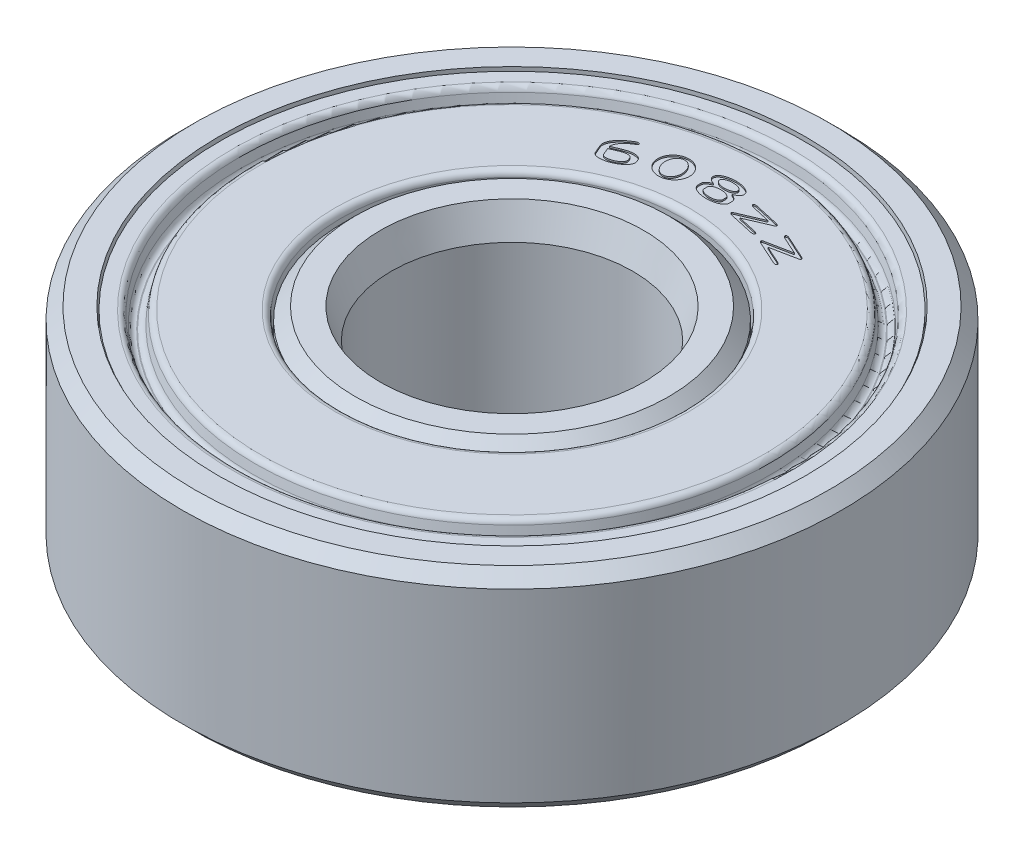
from build123d import *

# Parameters (mm, degrees)
SKETCH1_W             = 1.2
SKETCH1_H             = 6.98
CHAMF_OUTER_RACE_SIZE = 0.4
SKETCH2_W             = 1.6
SKETCH2_H             = 6.98
CHAMF_SMALL_SIZE      = 0.4
CHAMF_AXLE_SIZE       = 1
CHAMF_AXLE_SIZE2      = 0.363970234
DRAFT_PINCH_ANGLE     = 12
FILLET_COVER_R        = 0.2
CUT_LABEL_DEPTH       = 0.05


with BuildPart() as part:
    # Sketch1 → outer race (revolve)
    with BuildSketch(Plane.XY, mode=Mode.PRIVATE) as outer_race_sk:
        with Locations((10.4, 0)):
            Rectangle(SKETCH1_W, SKETCH1_H)
    revolve(outer_race_sk.sketch.rotate(Axis((0, -3.941243986, 0), (0, 1, 0)), 90), axis=Axis((0, -3.941243986, 0), (0, 1, 0)))

    # chamf outer race
    chamf_outer_race_edges = [part.edges().sort_by_distance(p)[0] for p in [
        (0, -3.49, 11),
        (0, 3.49, 11),
    ]]
    chamfer(chamf_outer_race_edges, length=CHAMF_OUTER_RACE_SIZE)


with BuildPart() as body_2:
    # Sketch2 → inner race (revolve)
    with BuildSketch(Plane.XY, mode=Mode.PRIVATE) as inner_race_sk:
        with Locations((4.83, 0)):
            Rectangle(SKETCH2_W, SKETCH2_H)
    revolve(inner_race_sk.sketch.rotate(Axis((0, 0, 0), (0, 1, 0)), 90), axis=Axis((0, 0, 0), (0, 1, 0)))

    # chamf small
    chamf_small_edges = [body_2.edges().sort_by_distance(p)[0] for p in [
        (0, 3.49, 5.63),
        (0, -3.49, 5.63),
    ]]
    chamfer(chamf_small_edges, length=CHAMF_SMALL_SIZE)

    # chamf axle
    chamf_axle_edges = [body_2.edges().sort_by_distance(p)[0] for p in [
        (0, 3.49, 4.03),
        (0, -3.49, 4.03),
    ]]
    chamf_axle_side = [body_2.faces().sort_by_distance(p)[0] for p in [
        (0, 0, 4.03),
    ]]
    chamfer(chamf_axle_edges, length=CHAMF_AXLE_SIZE, length2=CHAMF_AXLE_SIZE2, reference=chamf_axle_side[0])


with BuildPart() as body_3:
    # Sketch3 → cover (revolve)
    with BuildSketch(Plane.XY, mode=Mode.PRIVATE) as cover_sk:
        Polygon((9.75, 3.39), (9.15, 3.39), (9.15, 2.79), (8.55, 2.79), (8.55, 3.39), (5.7, 3.39), (5.7, 2.29), (9.15, 2.29), (9.75, 2.79), align=None)
    revolve(cover_sk.sketch.rotate(Axis((0, 3.839, 0), (0, -1, 0)), 90), axis=Axis((0, 3.839, 0), (0, -1, 0)))

    # draft pinch
    draft_pinch_faces = [body_3.faces().sort_by_distance(p)[0] for p in [
        (0, 3.09, -8.55),
        (0, 3.09, -9.15),
    ]]
    draft(draft_pinch_faces, Plane(origin=(9.75, 3.39, 0), x_dir=(0, 0, 1), z_dir=(0, 1, 0)), DRAFT_PINCH_ANGLE)

    # fillet cover
    fillet_cover_edges = [body_3.edges().sort_by_distance(p)[0] for p in [
        (0, 3.39, -9.15),
        (0, 2.79, -9.022466063),
        (0, 2.79, -8.677533937),
        (0, 3.39, -8.55),
        (0, 3.39, -5.7),
    ]]
    fillet(fillet_cover_edges, radius=FILLET_COVER_R)


with BuildPart() as body_4:
    # Mirror5: mirrored copy
    add(body_3.part.mirror(Plane.ZX))


with BuildPart() as body_3_1:
    add(body_3.part)

    # Sketch4 → cut label (cut)
    with BuildSketch(Plane(origin=(0, 3.39, 0), x_dir=(1, 0, 0), z_dir=(0, 1, 0))):
        with BuildLine():
            add(Edge.make_bspline(
                [(-2.806483422, 6.910348433), (-2.829045855, 6.896840745), (-2.873183586, 6.870416348), (-2.935668374, 6.828223591), (-2.993679868, 6.785650593), (-3.046583734, 6.741842798), (-3.094904182, 6.697404886), (-3.138408426, 6.651962366), (-3.177078752, 6.605665621), (-3.210781015, 6.558866241), (-3.239268513, 6.512390177), (-3.262041063, 6.466698418), (-3.279173411, 6.422217722), (-3.290543781, 6.37887429), (-3.296311521, 6.336725271), (-3.295806067, 6.295764374), (-3.290085588, 6.255878805), (-3.281246396, 6.230747933), (-3.276829268, 6.218189515)],
                knots=[0, 0, 0, 0, 1.400748775, 2.740212976, 4.015107812, 5.232869961, 6.397616894, 7.510704464, 8.581957721, 9.608704923, 10.580584922, 11.48293119, 12.324898009, 13.115438236, 13.865348873, 14.583670017, 15.292230549, 16, 16, 16, 16], degree=3))
            Line((-3.276829268, 6.218189515), (-3.158213049, 5.942042252))
            add(Edge.make_bspline(
                [(-3.158213049, 5.942042252), (-3.154000662, 5.934303078), (-3.145552158, 5.918781136), (-3.127555249, 5.898877353), (-3.106332001, 5.881450871), (-3.08121262, 5.867329347), (-3.052644192, 5.855901096), (-3.020459872, 5.847544172), (-2.984747904, 5.84168841), (-2.94578698, 5.838831709), (-2.904361647, 5.838656673), (-2.861337809, 5.841415853), (-2.816993967, 5.846649475), (-2.771550465, 5.855090495), (-2.724822075, 5.866344083), (-2.676930323, 5.880494389), (-2.627584045, 5.897009043), (-2.594786385, 5.91022534), (-2.57804878, 5.916970003)],
                knots=[0, 0, 0, 0, 0.672690361, 1.349169872, 2.038753605, 2.768525676, 3.546035807, 4.389252222, 5.309597856, 6.313971281, 7.377597942, 8.479596538, 9.61352349, 10.795023913, 12.016946269, 13.292660744, 14.618365668, 16, 16, 16, 16], degree=3))
            add(Edge.make_bspline(
                [(-2.57804878, 5.916970003), (-2.561530567, 5.924577636), (-2.529158651, 5.939486856), (-2.482546385, 5.963343509), (-2.439172421, 5.988693212), (-2.398649493, 6.014807046), (-2.361170718, 6.042141242), (-2.326522682, 6.070247893), (-2.295141111, 6.099706271), (-2.266771301, 6.129626797), (-2.242397704, 6.15997359), (-2.221651141, 6.189498163), (-2.206202008, 6.218831285), (-2.194571341, 6.247192359), (-2.188064898, 6.275189682), (-2.185524295, 6.302467955), (-2.188162771, 6.329156139), (-2.193344976, 6.345966716), (-2.195934959, 6.354368377)],
                knots=[0, 0, 0, 0, 1.391807051, 2.727623106, 4.005627591, 5.235351133, 6.41565081, 7.554313828, 8.647572075, 9.70772971, 10.707048161, 11.624662627, 12.464383325, 13.239517717, 13.963982062, 14.655986802, 15.328283482, 16, 16, 16, 16], degree=3))
            Line((-2.195934959, 6.354368377), (-2.235224927, 6.446126348))
            add(Edge.make_bspline(
                [(-2.235224927, 6.446126348), (-2.239560761, 6.453785023), (-2.248235672, 6.469108099), (-2.265904826, 6.489217983), (-2.287118016, 6.506419778), (-2.311978966, 6.520770415), (-2.340383964, 6.532250116), (-2.372450562, 6.540957783), (-2.408078496, 6.546698518), (-2.446894648, 6.549524347), (-2.488116168, 6.550019325), (-2.531088241, 6.547221335), (-2.57540325, 6.541715462), (-2.620995927, 6.533320757), (-2.667849803, 6.522037449), (-2.716036891, 6.508024291), (-2.765512273, 6.490881286), (-2.798562985, 6.477611001), (-2.815447154, 6.470831791)],
                knots=[0, 0, 0, 0, 0.672317284, 1.34513718, 2.034466086, 2.754989876, 3.534165665, 4.373424572, 5.293430104, 6.292261608, 7.350346974, 8.446761668, 9.586045226, 10.767109042, 11.993623484, 13.273845404, 14.607326381, 16, 16, 16, 16], degree=3))
            Line((-2.815447154, 6.470831791), (-3.097652677, 6.350034186))
            add(Edge.make_bspline(
                [(-3.097652677, 6.350034186), (-3.098341541, 6.359470756), (-3.09973875, 6.378610759), (-3.097253088, 6.407873176), (-3.091256675, 6.437690768), (-3.081763736, 6.468090873), (-3.068936302, 6.499094727), (-3.052165783, 6.5304669), (-3.032245495, 6.562657751), (-3.008661232, 6.59513153), (-2.982085699, 6.627789814), (-2.952516937, 6.660173873), (-2.919999128, 6.692047187), (-2.884424062, 6.723319667), (-2.846312786, 6.754479374), (-2.80502592, 6.78485758), (-2.761236537, 6.815342775), (-2.730376911, 6.834455558), (-2.714634146, 6.844205775)],
                knots=[0, 0, 0, 0, 0.693157688, 1.40591772, 2.145662096, 2.920625492, 3.73832622, 4.603060376, 5.527041968, 6.513202247, 7.544713858, 8.6141253, 9.728137391, 10.88289518, 12.087490624, 13.337869906, 14.641937916, 16, 16, 16, 16], degree=3))
            add(Edge.make_bspline(
                [(-2.714634146, 6.844205775), (-2.710107956, 6.84703817), (-2.701408923, 6.852481843), (-2.689837689, 6.861546111), (-2.680278366, 6.871034388), (-2.672805926, 6.88065253), (-2.66728115, 6.890247746), (-2.664367195, 6.899610176), (-2.663694346, 6.908724141), (-2.665403847, 6.914218028), (-2.666260163, 6.916970003)],
                knots=[0, 0, 0, 0, 1.360779643, 2.615326751, 3.739128595, 4.786082052, 5.713957791, 6.544593936, 7.270964174, 8, 8, 8, 8], degree=3))
            add(Edge.make_bspline(
                [(-2.666260163, 6.916970003), (-2.66861019, 6.920388605), (-2.673434343, 6.92740634), (-2.685859913, 6.933982852), (-2.701338751, 6.937426061), (-2.719931577, 6.937425087), (-2.740426748, 6.935083879), (-2.762063211, 6.929533637), (-2.784403308, 6.92151547), (-2.798990275, 6.914088394), (-2.806483422, 6.910348433)],
                knots=[0, 0, 0, 0, 0.647737067, 1.329679637, 2.156280584, 3.142479087, 4.25379808, 5.413070233, 6.667464896, 8, 8, 8, 8], degree=3))
        make_face()
        with BuildLine():
            add(Edge.make_bspline(
                [(-2.77557641, 6.378047238), (-2.765384698, 6.382082329), (-2.745391054, 6.389998189), (-2.715602801, 6.400393758), (-2.686618232, 6.4089062), (-2.658604346, 6.416031502), (-2.631252503, 6.420723526), (-2.604834015, 6.424367791), (-2.579223641, 6.426008646), (-2.554710573, 6.425773073), (-2.531647657, 6.424114446), (-2.510481855, 6.420476549), (-2.491439418, 6.415261721), (-2.474500764, 6.408361215), (-2.459730097, 6.399623238), (-2.447166216, 6.389080155), (-2.436495005, 6.377057161), (-2.431406682, 6.367758754), (-2.428861789, 6.363108214)],
                knots=[0, 0, 0, 0, 1.401694666, 2.749781931, 4.032762629, 5.26415454, 6.443610575, 7.579525791, 8.673393419, 9.721778453, 10.712552617, 11.627009445, 12.463661788, 13.232763397, 13.959355913, 14.648242704, 15.32392699, 16, 16, 16, 16], degree=3))
            Line((-2.428861789, 6.363108214), (-2.389465431, 6.271521737))
            add(Edge.make_bspline(
                [(-2.389465431, 6.271521737), (-2.387930136, 6.266383523), (-2.384890595, 6.256211006), (-2.3832949, 6.240157799), (-2.384373914, 6.223770376), (-2.38809816, 6.206899026), (-2.394744772, 6.189788118), (-2.404125412, 6.172374822), (-2.415953928, 6.154426595), (-2.430557103, 6.136366426), (-2.447366148, 6.118404135), (-2.466119412, 6.100812086), (-2.486971396, 6.084122358), (-2.509259529, 6.067435788), (-2.53381216, 6.052032854), (-2.559790078, 6.036566565), (-2.587956117, 6.022266167), (-2.607490965, 6.013247939), (-2.617479675, 6.008636669)],
                knots=[0, 0, 0, 0, 0.682793168, 1.351778156, 2.044455208, 2.769938109, 3.546721469, 4.377844085, 5.288621324, 6.284619784, 7.336271084, 8.424564057, 9.560959292, 10.7414476, 11.973565428, 13.255584212, 14.596703964, 16, 16, 16, 16], degree=3))
            add(Edge.make_bspline(
                [(-2.617479675, 6.008636669), (-2.627544485, 6.004628591), (-2.647264188, 5.996775673), (-2.67673532, 5.98657026), (-2.705514144, 5.978232255), (-2.733500287, 5.971432465), (-2.760800334, 5.966606316), (-2.787249312, 5.963219471), (-2.812988846, 5.961863205), (-2.837713144, 5.961932549), (-2.86102232, 5.963961902), (-2.882405469, 5.967509631), (-2.901637326, 5.97276106), (-2.918756577, 5.979579766), (-2.933568867, 5.988455973), (-2.94633432, 5.998844116), (-2.956975964, 6.011008051), (-2.962210654, 6.020256167), (-2.964837398, 6.024896832)],
                knots=[0, 0, 0, 0, 1.384198562, 2.712021941, 3.983239889, 5.211611418, 6.39013056, 7.524053428, 8.616537756, 9.681403752, 10.680734164, 11.602996118, 12.447324553, 13.223819296, 13.949834647, 14.64483809, 15.319985651, 16, 16, 16, 16], degree=3))
            Line((-2.964837398, 6.024896832), (-3.063184785, 6.254780438))
            Line((-3.063184785, 6.254780438), (-2.77557641, 6.378047238))
        make_face(mode=Mode.SUBTRACT)
        with BuildLine():
            add(Edge.make_bspline(
                [(-1.926766627, 6.707162245), (-1.922492138, 6.690201213), (-1.914106113, 6.656925738), (-1.895805515, 6.609483316), (-1.874191138, 6.564999421), (-1.84833248, 6.523613033), (-1.818639219, 6.485271518), (-1.784759832, 6.450167483), (-1.747277404, 6.417837059), (-1.705937138, 6.389256814), (-1.662054815, 6.36437662), (-1.616476762, 6.343667698), (-1.569366202, 6.327990214), (-1.520984981, 6.316795934), (-1.471182258, 6.309942213), (-1.420009791, 6.308379836), (-1.367474543, 6.310783301), (-1.332385045, 6.316225226), (-1.314534983, 6.318993538)],
                knots=[0, 0, 0, 0, 1.043163421, 2.046559294, 3.028581703, 3.991323237, 4.953894901, 5.917731381, 6.898479079, 7.903600988, 8.912279597, 9.905922998, 10.886745725, 11.870606467, 12.866288483, 13.881946532, 14.922544126, 16, 16, 16, 16], degree=3))
            add(Edge.make_bspline(
                [(-1.314534983, 6.318993538), (-1.29683004, 6.323429425), (-1.262069437, 6.332138524), (-1.212307587, 6.35022278), (-1.165698083, 6.371805239), (-1.122138631, 6.397077695), (-1.081764408, 6.426222379), (-1.044603589, 6.459178132), (-1.010429013, 6.495681178), (-0.98004884, 6.535815049), (-0.953253942, 6.57815311), (-0.931158001, 6.622357429), (-0.913764972, 6.667810637), (-0.901288304, 6.714610885), (-0.893794513, 6.762712856), (-0.890969071, 6.812123371), (-0.892926121, 6.862920462), (-0.89795619, 6.896873322), (-0.900510593, 6.914115489)],
                knots=[0, 0, 0, 0, 1.088080662, 2.136258759, 3.152318712, 4.148291234, 5.135270964, 6.117208026, 7.106476633, 8.112725593, 9.115063997, 10.090953949, 11.055347293, 12.013011754, 12.974352354, 13.953916729, 14.960944357, 16, 16, 16, 16], degree=3))
            add(Edge.make_bspline(
                [(-0.900510593, 6.914115489), (-0.904789178, 6.931083421), (-0.91321178, 6.964485618), (-0.931303301, 7.01216761), (-0.95322497, 7.05671318), (-0.978516688, 7.098548992), (-1.008502717, 7.136777032), (-1.041969784, 7.17218933), (-1.079416392, 7.204479333), (-1.120482284, 7.233257686), (-1.16405924, 7.258446459), (-1.209746233, 7.278847695), (-1.256757122, 7.294761062), (-1.305290779, 7.306047831), (-1.355268694, 7.312435842), (-1.406755518, 7.31452647), (-1.459691672, 7.311672284), (-1.495125602, 7.306282362), (-1.513112219, 7.303546384)],
                knots=[0, 0, 0, 0, 1.041492845, 2.050229235, 3.030089823, 3.995454238, 4.9559069, 5.917757016, 6.893288033, 7.895206534, 8.900159118, 9.886280332, 10.870054342, 11.851749217, 12.848707433, 13.866313984, 14.916919592, 16, 16, 16, 16], degree=3))
            add(Edge.make_bspline(
                [(-1.513112219, 7.303546384), (-1.530616268, 7.299184119), (-1.56512062, 7.29058513), (-1.614517879, 7.272495869), (-1.661006688, 7.250987377), (-1.704261548, 7.22536761), (-1.744673475, 7.196337032), (-1.781830033, 7.163363472), (-1.815992302, 7.126801871), (-1.846583674, 7.086736368), (-1.873612972, 7.044346429), (-1.895912402, 7.000023206), (-1.913234934, 6.954374205), (-1.925759492, 6.907378371), (-1.933422736, 6.859089856), (-1.936536143, 6.809406641), (-1.934502245, 6.758400174), (-1.929482385, 6.724311508), (-1.926766627, 6.707162245)],
                knots=[0, 0, 0, 0, 1.074445414, 2.117969636, 3.129539367, 4.123255318, 5.109428536, 6.090563206, 7.079023431, 8.08690375, 9.090577677, 10.071089022, 11.038468318, 11.995350223, 12.964514291, 13.947549736, 14.957788958, 16, 16, 16, 16], degree=3))
        make_face()
        with BuildLine():
            add(Edge.make_bspline(
                [(-1.720330842, 6.74879239), (-1.722590057, 6.762614112), (-1.727020971, 6.78972214), (-1.730253802, 6.830111197), (-1.73045861, 6.869240386), (-1.727903978, 6.907175476), (-1.722254151, 6.943847361), (-1.71341255, 6.979176114), (-1.701857188, 7.01330106), (-1.687279333, 7.045782497), (-1.670356176, 7.076174539), (-1.651221908, 7.103814544), (-1.629907072, 7.128353399), (-1.606816992, 7.150106581), (-1.581202413, 7.168340793), (-1.553715707, 7.183562025), (-1.524237917, 7.196020512), (-1.503503129, 7.201553885), (-1.492990268, 7.204359392)],
                knots=[0, 0, 0, 0, 1.193047247, 2.339879085, 3.448360255, 4.524806428, 5.576491158, 6.605654909, 7.624402414, 8.642609942, 9.635140828, 10.584855443, 11.501623133, 12.400325388, 13.281518717, 14.173109135, 15.07373787, 16, 16, 16, 16], degree=3))
            add(Edge.make_bspline(
                [(-1.492990268, 7.204359392), (-1.482105249, 7.205901896), (-1.460611442, 7.208947759), (-1.428318345, 7.209037103), (-1.396842212, 7.20553697), (-1.366060622, 7.198718463), (-1.3362376, 7.187662114), (-1.307007104, 7.173431433), (-1.278639931, 7.155361004), (-1.251366946, 7.133818702), (-1.225517874, 7.109455785), (-1.201876115, 7.082378539), (-1.180203868, 7.053233727), (-1.160811623, 7.021640272), (-1.14411032, 6.98754804), (-1.129139907, 6.951421288), (-1.116464812, 6.912901335), (-1.110073569, 6.886118885), (-1.106811406, 6.872448823)],
                knots=[0, 0, 0, 0, 0.934578771, 1.845440575, 2.738617637, 3.625278138, 4.520684895, 5.438525193, 6.386923395, 7.376411204, 8.391823928, 9.404861031, 10.43101744, 11.479044359, 12.554119965, 13.657870913, 14.804551054, 16, 16, 16, 16], degree=3))
            add(Edge.make_bspline(
                [(-1.106811406, 6.872448823), (-1.104508114, 6.858654846), (-1.099998568, 6.83164804), (-1.096790088, 6.791345037), (-1.096555736, 6.752348428), (-1.099204795, 6.714502696), (-1.104564727, 6.677887531), (-1.113221397, 6.64255948), (-1.12456539, 6.608433405), (-1.138946234, 6.575954501), (-1.155701354, 6.545472633), (-1.174757047, 6.517753442), (-1.196035363, 6.493145833), (-1.219427779, 6.471615241), (-1.244882417, 6.452906328), (-1.272830739, 6.437782151), (-1.30255279, 6.425042714), (-1.323594198, 6.419543031), (-1.334250431, 6.416757766)],
                knots=[0, 0, 0, 0, 1.189872389, 2.329614967, 3.436799416, 4.506233944, 5.555817509, 6.582401608, 7.598109328, 8.612785265, 9.601350339, 10.554691983, 11.470387222, 12.364121468, 13.255713782, 14.151306415, 15.063745757, 16, 16, 16, 16], degree=3))
            add(Edge.make_bspline(
                [(-1.334250431, 6.416757766), (-1.345070447, 6.415298115), (-1.366374064, 6.412424198), (-1.398302344, 6.412303885), (-1.429584729, 6.415671589), (-1.460047119, 6.423215178), (-1.490046083, 6.433681649), (-1.519054515, 6.448393621), (-1.547356424, 6.466625336), (-1.574863378, 6.488093334), (-1.600907833, 6.512470037), (-1.624729796, 6.539557847), (-1.646692233, 6.56861173), (-1.665809155, 6.600333374), (-1.683340233, 6.633935261), (-1.698053386, 6.670127957), (-1.710726483, 6.708495959), (-1.717160431, 6.735134324), (-1.720330842, 6.74879239)],
                knots=[0, 0, 0, 0, 0.929846853, 1.830782852, 2.714072986, 3.604939017, 4.499988242, 5.416849813, 6.37004077, 7.365841594, 8.387269397, 9.405934348, 10.437370018, 11.487265704, 12.559167583, 13.664886661, 14.813611479, 16, 16, 16, 16], degree=3))
        make_face(mode=Mode.SUBTRACT)
        with BuildLine():
            add(Edge.make_bspline(
                [(0.544331605, 6.800877123), (0.544122713, 6.805870226), (0.543703562, 6.815889102), (0.540862602, 6.830734729), (0.536949153, 6.845467255), (0.530866388, 6.859877275), (0.523126753, 6.873956924), (0.513990698, 6.887971906), (0.502769461, 6.901351457), (0.490271927, 6.914785619), (0.476030825, 6.927720424), (0.460343436, 6.94014532), (0.443162343, 6.951911063), (0.424594747, 6.963338412), (0.404479175, 6.97433202), (0.382775494, 6.984571739), (0.35966191, 6.994427434), (0.343637715, 7.000369225), (0.335413525, 7.003418765)],
                knots=[0, 0, 0, 0, 0.774995842, 1.555062534, 2.341206474, 3.138325435, 3.976261637, 4.834104086, 5.73123599, 6.683892397, 7.681716728, 8.715175184, 9.78907366, 10.913174744, 12.099548968, 13.346552054, 14.638155563, 16, 16, 16, 16], degree=3))
            add(Edge.make_bspline(
                [(0.335413525, 7.003418765), (0.343712055, 7.006382722), (0.359904416, 7.012166091), (0.383082556, 7.022061354), (0.404930309, 7.032131612), (0.425225944, 7.042952799), (0.444139332, 7.054052262), (0.461543189, 7.065686341), (0.477459582, 7.077878773), (0.491793538, 7.090645001), (0.504746224, 7.103650927), (0.515894173, 7.117097478), (0.525582788, 7.130665557), (0.533271224, 7.144663703), (0.539723823, 7.158643378), (0.544229428, 7.172982058), (0.54688991, 7.187606978), (0.547503071, 7.197446625), (0.547811899, 7.202402505)],
                knots=[0, 0, 0, 0, 1.370019647, 2.673227082, 3.917567966, 5.109977517, 6.248332408, 7.326593956, 8.363394518, 9.363464124, 10.309635966, 11.214796138, 12.077060436, 12.897772126, 13.694741734, 14.467814473, 15.228292544, 16, 16, 16, 16], degree=3))
            add(Edge.make_bspline(
                [(0.547811899, 7.202402505), (0.546957136, 7.21119338), (0.545250392, 7.228746525), (0.537302352, 7.25435168), (0.524561634, 7.278558678), (0.507645618, 7.30175767), (0.486264564, 7.323783164), (0.46032448, 7.344496185), (0.430106222, 7.364225944), (0.395625053, 7.382407728), (0.357994753, 7.399375791), (0.317539075, 7.414163315), (0.274863643, 7.426982759), (0.229767077, 7.437484481), (0.182342845, 7.445985587), (0.132496183, 7.452485422), (0.080261937, 7.456735157), (0.044635005, 7.457904083), (0.026470436, 7.458500066)],
                knots=[0, 0, 0, 0, 0.674541776, 1.346888617, 2.035526967, 2.759328859, 3.536610709, 4.377024273, 5.294390425, 6.294024165, 7.356781801, 8.450791946, 9.587405725, 10.764398088, 11.99178024, 13.272693289, 14.60946898, 16, 16, 16, 16], degree=3))
            add(Edge.make_bspline(
                [(0.026470436, 7.458500066), (0.008443598, 7.458257233), (-0.026898563, 7.457781152), (-0.078793434, 7.454305022), (-0.12840273, 7.448507442), (-0.175903188, 7.441250782), (-0.221043673, 7.431146857), (-0.264069598, 7.41929375), (-0.304755038, 7.404973983), (-0.342977519, 7.389019229), (-0.377686411, 7.37099239), (-0.40860679, 7.352117147), (-0.434911678, 7.331638932), (-0.456867248, 7.310107559), (-0.474526833, 7.287358985), (-0.487515422, 7.263277992), (-0.496253808, 7.237912631), (-0.498175664, 7.220353393), (-0.499139321, 7.211548847)],
                knots=[0, 0, 0, 0, 1.380361711, 2.706240901, 3.980422942, 5.204375577, 6.383835187, 7.520494932, 8.619814564, 9.684570696, 10.689291507, 11.612072118, 12.454768506, 13.236162745, 13.961482924, 14.650883385, 15.323526452, 16, 16, 16, 16], degree=3))
            add(Edge.make_bspline(
                [(-0.499139321, 7.211548847), (-0.499007362, 7.206589182), (-0.498745122, 7.196732887), (-0.49586233, 7.182101758), (-0.491674117, 7.167608712), (-0.485514336, 7.153386537), (-0.47761192, 7.139458673), (-0.4683595, 7.125568134), (-0.456937436, 7.112191092), (-0.439653277, 7.093936073), (-0.413697959, 7.072421026), (-0.377720364, 7.048903644), (-0.336197603, 7.027315312), (-0.306097545, 7.01521647), (-0.290399483, 7.00890657)],
                knots=[0, 0, 0, 0, 0.578788505, 1.150220961, 1.736380124, 2.339300608, 2.955993338, 3.605937415, 4.286085759, 5.008419936, 6.542081517, 8.210841872, 10.023843055, 12, 12, 12, 12], degree=3))
            add(Edge.make_bspline(
                [(-0.290399483, 7.00890657), (-0.298480412, 7.005975298), (-0.314332097, 7.000225267), (-0.337306209, 6.990933316), (-0.358881312, 6.980974186), (-0.379052869, 6.97042841), (-0.397732996, 6.959225611), (-0.415145665, 6.947617389), (-0.431149582, 6.9354505), (-0.445827475, 6.922911136), (-0.458889097, 6.909876229), (-0.470291575, 6.896518305), (-0.479964477, 6.882775884), (-0.487903794, 6.868737812), (-0.494248473, 6.854446509), (-0.49904122, 6.839906033), (-0.50190549, 6.825003341), (-0.502500518, 6.814947693), (-0.502797857, 6.80992283)],
                knots=[0, 0, 0, 0, 1.336255979, 2.621221898, 3.851141179, 5.028907246, 6.157814605, 7.235702201, 8.280510962, 9.281231849, 10.234493587, 11.146118266, 12.008083523, 12.842852221, 13.649164085, 14.435204339, 15.218062946, 16, 16, 16, 16], degree=3))
            Line((-0.502797857, 6.80992283), (-0.503522736, 6.710323975))
            add(Edge.make_bspline(
                [(-0.503522736, 6.710323975), (-0.502740047, 6.701455896), (-0.501186557, 6.683854443), (-0.492774278, 6.658374428), (-0.480201134, 6.634105858), (-0.463010662, 6.610972617), (-0.441462166, 6.589013044), (-0.41549249, 6.568168451), (-0.385079041, 6.548513701), (-0.350450156, 6.530376245), (-0.312730396, 6.513301514), (-0.272168869, 6.498615578), (-0.229446516, 6.48573864), (-0.184408841, 6.475274622), (-0.137127573, 6.46674008), (-0.087549019, 6.46026039), (-0.035655249, 6.455993812), (-0.000298641, 6.454826842), (0.017730598, 6.454231774)],
                knots=[0, 0, 0, 0, 0.679648559, 1.348973239, 2.03800708, 2.765283297, 3.546618511, 4.387514733, 5.309750515, 6.314534513, 7.377902501, 8.477409326, 9.614675873, 10.792344193, 12.0153267, 13.291832093, 14.619035915, 16, 16, 16, 16], degree=3))
            add(Edge.make_bspline(
                [(0.017730598, 6.454231774), (0.035894015, 6.454466004), (0.071509027, 6.454925286), (0.123719354, 6.458518788), (0.173661251, 6.463861288), (0.221271422, 6.471626404), (0.266606294, 6.481319288), (0.309620445, 6.493027944), (0.350225205, 6.507090304), (0.388135882, 6.523158727), (0.422720964, 6.540888788), (0.453361245, 6.559690493), (0.479701175, 6.579590287), (0.501461539, 6.600799229), (0.518882754, 6.623093013), (0.531679282, 6.646638536), (0.54043602, 6.671283122), (0.542373199, 6.688379282), (0.543340354, 6.6969147)],
                knots=[0, 0, 0, 0, 1.397007189, 2.739265871, 4.02379061, 5.259234974, 6.447995753, 7.588389377, 8.686031066, 9.750791894, 10.753022928, 11.672788372, 12.512908643, 13.286798271, 14.003949298, 14.680228572, 15.34109176, 16, 16, 16, 16], degree=3))
            Line((0.543340354, 6.6969147), (0.544331605, 6.800877123))
        make_face()
        with BuildLine():
            add(Edge.make_bspline(
                [(0.018638484, 6.554054325), (0.007760862, 6.554337333), (-0.013518634, 6.554890971), (-0.04467258, 6.557641463), (-0.074378862, 6.561467348), (-0.102706936, 6.566454252), (-0.129612406, 6.573048937), (-0.155170345, 6.580653969), (-0.179315553, 6.589686119), (-0.201890212, 6.599716018), (-0.222563432, 6.610640059), (-0.240459148, 6.622824357), (-0.256207249, 6.635018062), (-0.268850208, 6.64846264), (-0.279340998, 6.662257263), (-0.286605512, 6.67706489), (-0.291613515, 6.6924085), (-0.292563353, 6.702974846), (-0.29304176, 6.708296814)],
                knots=[0, 0, 0, 0, 1.38968859, 2.718597173, 3.992807772, 5.21508447, 6.390567245, 7.529545856, 8.619462328, 9.680970366, 10.68388383, 11.600810911, 12.444213333, 13.221625766, 13.952097778, 14.648771015, 15.319424415, 16, 16, 16, 16], degree=3))
            Line((-0.29304176, 6.708296814), (-0.292083061, 6.80820015))
            add(Edge.make_bspline(
                [(-0.292083061, 6.80820015), (-0.29149883, 6.813482236), (-0.290334085, 6.82401279), (-0.28532966, 6.83932154), (-0.277344594, 6.85363783), (-0.26706175, 6.867483923), (-0.25397808, 6.880391867), (-0.238230518, 6.892514624), (-0.219874102, 6.903737827), (-0.199206999, 6.914510646), (-0.17648439, 6.924090536), (-0.152151207, 6.932428353), (-0.126487729, 6.939511953), (-0.099431401, 6.945451271), (-0.070973373, 6.949812606), (-0.041203621, 6.953063538), (-0.010075408, 6.955123106), (0.011155619, 6.955474878), (0.021998891, 6.955654538)],
                knots=[0, 0, 0, 0, 0.679143418, 1.353964458, 2.044873288, 2.77005472, 3.55517126, 4.389763394, 5.309249182, 6.306351837, 7.371325837, 8.463128526, 9.597485927, 10.778287342, 12.007605402, 13.281649209, 14.611663273, 16, 16, 16, 16], degree=3))
            add(Edge.make_bspline(
                [(0.021998891, 6.955654538), (0.032979653, 6.955356461), (0.054496364, 6.954772383), (0.085966056, 6.952084025), (0.115973777, 6.948108813), (0.144572992, 6.943563803), (0.171542277, 6.936770915), (0.197122028, 6.929428009), (0.221277927, 6.920699165), (0.243600382, 6.910531695), (0.264108479, 6.899852284), (0.281896688, 6.8879042), (0.297331924, 6.875583915), (0.310077202, 6.862386796), (0.319947413, 6.84833334), (0.327484666, 6.833850863), (0.33208132, 6.818447048), (0.333080207, 6.807918557), (0.333584257, 6.802605757)],
                knots=[0, 0, 0, 0, 1.403821957, 2.750777272, 4.034331964, 5.272901298, 6.449081853, 7.5862664, 8.673834604, 9.728071239, 10.719854124, 11.625313613, 12.462480878, 13.240354793, 13.961135726, 14.650487987, 15.319020418, 16, 16, 16, 16], degree=3))
            Line((0.333584257, 6.802605757), (0.332891929, 6.703000948))
            add(Edge.make_bspline(
                [(0.332891929, 6.703000948), (0.332297507, 6.697614639), (0.331123535, 6.686976799), (0.325981511, 6.671600951), (0.318406932, 6.657030538), (0.307991101, 6.643287167), (0.295102731, 6.630297011), (0.279601543, 6.617987961), (0.26145843, 6.606470884), (0.240804324, 6.595839616), (0.218216909, 6.586229728), (0.194067644, 6.577633103), (0.168425158, 6.570280612), (0.141229604, 6.564546576), (0.112628549, 6.559754136), (0.082553476, 6.556649843), (0.051025331, 6.554552343), (0.029522773, 6.554205579), (0.018638484, 6.554054325)],
                knots=[0, 0, 0, 0, 0.689676942, 1.362096895, 2.054119286, 2.776720443, 3.552955616, 4.383139541, 5.296658823, 6.290213678, 7.343448263, 8.426065462, 9.5587307, 10.74377723, 11.970092771, 13.256788947, 14.599321401, 16, 16, 16, 16], degree=3))
        make_face(mode=Mode.SUBTRACT)
        with BuildLine():
            add(Edge.make_bspline(
                [(0.02304413, 7.056866507), (0.012190201, 7.057186599), (-0.009058019, 7.057813228), (-0.040207703, 7.060236149), (-0.070000068, 7.064056616), (-0.098318874, 7.06940488), (-0.125377491, 7.075615062), (-0.15089912, 7.083314049), (-0.175042105, 7.092332726), (-0.197644193, 7.102325634), (-0.218153156, 7.113361491), (-0.236316082, 7.125008385), (-0.251913702, 7.137282925), (-0.264554393, 7.150602803), (-0.274772667, 7.164314043), (-0.282237415, 7.178773015), (-0.287101946, 7.193978688), (-0.288080467, 7.204469128), (-0.288570215, 7.209719578)],
                knots=[0, 0, 0, 0, 1.390503779, 2.722123108, 3.999610325, 5.235125591, 6.411617085, 7.553524566, 8.646243746, 9.71048144, 10.715973884, 11.625709271, 12.471280493, 13.250692034, 13.970914369, 14.653901749, 15.326279726, 16, 16, 16, 16], degree=3))
            add(Edge.make_bspline(
                [(-0.288570215, 7.209719578), (-0.28803848, 7.215047818), (-0.286979486, 7.225659457), (-0.281562959, 7.240844538), (-0.27391525, 7.255418746), (-0.263491561, 7.269148517), (-0.250389644, 7.282150485), (-0.234679038, 7.294227624), (-0.216356193, 7.305695108), (-0.195622924, 7.316213714), (-0.172937593, 7.32602804), (-0.148540311, 7.334202841), (-0.12283361, 7.34135479), (-0.095835433, 7.347250971), (-0.067388106, 7.351683287), (-0.03761035, 7.354861942), (-0.006419936, 7.357007802), (0.0148136, 7.35718835), (0.025657427, 7.357280554)],
                knots=[0, 0, 0, 0, 0.682646129, 1.359547277, 2.04570487, 2.782325139, 3.55443711, 4.400394331, 5.31165661, 6.315506169, 7.371493525, 8.470451955, 9.603727434, 10.783402631, 12.002987878, 13.284431428, 14.613176958, 16, 16, 16, 16], degree=3))
            add(Edge.make_bspline(
                [(0.025657427, 7.357280554), (0.036638572, 7.356986258), (0.058088532, 7.356411396), (0.089552841, 7.353676013), (0.119503205, 7.349777507), (0.148091183, 7.345161099), (0.174997801, 7.338399729), (0.200578118, 7.331054544), (0.224729976, 7.322320765), (0.24706716, 7.31217392), (0.267575117, 7.301397342), (0.285528167, 7.28967396), (0.300732018, 7.277138197), (0.313578285, 7.264152769), (0.323617323, 7.250217691), (0.331181006, 7.235621405), (0.335713283, 7.220132838), (0.336731921, 7.209542897), (0.337242793, 7.204231774)],
                knots=[0, 0, 0, 0, 1.403906922, 2.742314102, 4.034535668, 5.26464346, 6.440895202, 7.578148577, 8.665782605, 9.720083047, 10.711925959, 11.624658576, 12.455175962, 13.226853548, 13.952706753, 14.642100736, 15.318979202, 16, 16, 16, 16], degree=3))
            add(Edge.make_bspline(
                [(0.337242793, 7.204231774), (0.336693099, 7.198976271), (0.335600337, 7.188528628), (0.330442247, 7.173424969), (0.322871838, 7.159058978), (0.312460472, 7.145508764), (0.299499136, 7.132749226), (0.284141503, 7.120391576), (0.265858228, 7.109157153), (0.245286952, 7.098464681), (0.222628885, 7.088848885), (0.198426195, 7.080251876), (0.172717422, 7.073226223), (0.145583079, 7.067301892), (0.117009066, 7.062717148), (0.086976353, 7.059194827), (0.055493923, 7.057219623), (0.03399332, 7.056856307), (0.02304413, 7.056866507)],
                knots=[0, 0, 0, 0, 0.674528785, 1.340925352, 2.027554026, 2.745609843, 3.518251905, 4.351177079, 5.263064983, 6.259900533, 7.316612875, 8.410978696, 9.545032224, 10.725517324, 11.964440288, 13.247730926, 14.594696392, 16, 16, 16, 16], degree=3))
        make_face(mode=Mode.SUBTRACT)
        with BuildLine():
            add(Edge.make_bspline(
                [(0.848725862, 6.473319524), (0.848457458, 6.469717204), (0.847913851, 6.462421313), (0.852190617, 6.451383254), (0.860058216, 6.441047077), (0.871156343, 6.430979966), (0.885085703, 6.421629782), (0.901443931, 6.41326579), (0.920132524, 6.406430423), (0.933433777, 6.402870908), (0.940375657, 6.401013209)],
                knots=[0, 0, 0, 0, 0.680608867, 1.378458183, 2.191464603, 3.141058795, 4.218305343, 5.378233992, 6.631709058, 8, 8, 8, 8], degree=3))
            Line((0.940375657, 6.401013209), (1.757050065, 6.22013855))
            add(Edge.make_bspline(
                [(1.757050065, 6.22013855), (1.764071096, 6.2187586), (1.777562724, 6.216106883), (1.797405027, 6.21473935), (1.815738271, 6.21525362), (1.832399503, 6.217735836), (1.84667047, 6.222310249), (1.858332353, 6.228207034), (1.866766396, 6.236443921), (1.869383251, 6.243230154), (1.87066021, 6.246541664)],
                knots=[0, 0, 0, 0, 1.362759142, 2.618680785, 3.78159195, 4.85377029, 5.817578202, 6.62664191, 7.329836043, 8, 8, 8, 8], degree=3))
            add(Edge.make_bspline(
                [(1.87066021, 6.246541664), (1.870914498, 6.250091956), (1.871433261, 6.257334774), (1.867219668, 6.268284524), (1.859282629, 6.278531696), (1.847987913, 6.288228111), (1.834098224, 6.297595168), (1.817440019, 6.305262579), (1.798881961, 6.31234655), (1.785541121, 6.315718797), (1.778587039, 6.317476624)],
                knots=[0, 0, 0, 0, 0.673475753, 1.373932876, 2.179530146, 3.133552422, 4.207586677, 5.371921922, 6.630081124, 8, 8, 8, 8], degree=3))
            Line((1.778587039, 6.317476624), (1.153412171, 6.456113168))
            Line((1.153412171, 6.456113168), (1.977924882, 6.811314157))
            add(Edge.make_bspline(
                [(1.977924882, 6.811314157), (1.980945847, 6.812612018), (1.986637732, 6.815057354), (1.993410091, 6.820791721), (1.998775227, 6.827125994), (2.00022739, 6.832231105), (2.000944762, 6.834753046)],
                knots=[0, 0, 0, 0, 1.145893222, 2.15900963, 3.090544986, 4, 4, 4, 4], degree=3))
            add(Edge.make_bspline(
                [(2.000944762, 6.834753046), (2.00119904, 6.838303316), (2.001717783, 6.845546089), (1.997504359, 6.856496205), (1.989566531, 6.866741668), (1.978275541, 6.876446158), (1.964420066, 6.885743266), (1.947836791, 6.893576299), (1.929213545, 6.900505716), (1.915820687, 6.903917663), (1.908871592, 6.905688006)],
                knots=[0, 0, 0, 0, 0.673434943, 1.373849622, 2.179398076, 3.133362543, 4.207331716, 5.359941523, 6.630164135, 8, 8, 8, 8], degree=3))
            Line((1.908871592, 6.905688006), (1.09250365, 7.086749243))
            add(Edge.make_bspline(
                [(1.09250365, 7.086749243), (1.085442903, 7.08802977), (1.071891175, 7.090487491), (1.052062326, 7.092173685), (1.033715689, 7.091863311), (1.017180641, 7.089509272), (1.00284656, 7.085460238), (0.991409959, 7.079476033), (0.982831669, 7.071470563), (0.980257926, 7.064703477), (0.978993543, 7.061379063)],
                knots=[0, 0, 0, 0, 1.371710571, 2.632731231, 3.799079232, 4.872805496, 5.819674112, 6.631379192, 7.327648141, 8, 8, 8, 8], degree=3))
            add(Edge.make_bspline(
                [(0.978993543, 7.061379063), (0.978737686, 7.057827956), (0.978215722, 7.050583476), (0.982475634, 7.039594804), (0.99034269, 7.029258613), (1.00144056, 7.019190314), (1.015371955, 7.009845823), (1.031777986, 7.001428645), (1.050568867, 6.994685078), (1.063924967, 6.99109147), (1.070863462, 6.989224591)],
                knots=[0, 0, 0, 0, 0.670762581, 1.368397835, 2.181154869, 3.130457778, 4.207373885, 5.366946731, 6.632128776, 8, 8, 8, 8], degree=3))
            Line((1.070863462, 6.989224591), (1.696141544, 6.850774626))
            Line((1.696141544, 6.850774626), (0.871932718, 6.496944794))
            add(Edge.make_bspline(
                [(0.871932718, 6.496944794), (0.868872385, 6.49527894), (0.863185722, 6.492183476), (0.85613656, 6.486493597), (0.851015477, 6.480222576), (0.849461318, 6.47546884), (0.848725862, 6.473319524)],
                knots=[0, 0, 0, 0, 1.21736313, 2.262085115, 3.158720726, 4, 4, 4, 4], degree=3))
        make_face()
        with BuildLine():
            add(Edge.make_bspline(
                [(2.168081353, 6.158325528), (2.167044548, 6.154852269), (2.164934524, 6.147783775), (2.167275582, 6.136176976), (2.172165922, 6.124136017), (2.18128661, 6.112169553), (2.192901214, 6.100105246), (2.207383689, 6.088773599), (2.224011165, 6.07787793), (2.236422393, 6.071889751), (2.242869566, 6.068779113)],
                knots=[0, 0, 0, 0, 0.680271505, 1.384433594, 2.194112115, 3.14630057, 4.222750636, 5.379087768, 6.63853305, 8, 8, 8, 8], degree=3))
            Line((2.242869566, 6.068779113), (3.004718723, 5.723303456))
            add(Edge.make_bspline(
                [(3.004718723, 5.723303456), (3.011354273, 5.720502361), (3.024039209, 5.715147614), (3.043190327, 5.709646005), (3.061230543, 5.706252847), (3.078050871, 5.70536743), (3.092957959, 5.70675946), (3.105382867, 5.710604565), (3.115455636, 5.716609947), (3.119412081, 5.722730608), (3.121324851, 5.725689682)],
                knots=[0, 0, 0, 0, 1.372130797, 2.623051559, 3.791129132, 4.864516619, 5.825972962, 6.626642612, 7.336041258, 8, 8, 8, 8], degree=3))
            add(Edge.make_bspline(
                [(3.121324851, 5.725689682), (3.122348933, 5.72912188), (3.124444531, 5.736145251), (3.122229203, 5.747659648), (3.116905147, 5.759411029), (3.107693235, 5.771058984), (3.096071029, 5.783058787), (3.081412009, 5.794050766), (3.064639997, 5.80481671), (3.052222143, 5.81091091), (3.045715095, 5.814104316)],
                knots=[0, 0, 0, 0, 0.675129885, 1.381531045, 2.175118765, 3.127526008, 4.19813281, 5.36031009, 6.616782796, 8, 8, 8, 8], degree=3))
            Line((3.045715095, 5.814104316), (2.462688823, 6.078668595))
            Line((2.462688823, 6.078668595), (3.34279295, 6.256244576))
            add(Edge.make_bspline(
                [(3.34279295, 6.256244576), (3.345987518, 6.256881113), (3.35210989, 6.258101031), (3.359969802, 6.262238077), (3.366479165, 6.267481931), (3.369023057, 6.272124227), (3.370308591, 6.27447017)],
                knots=[0, 0, 0, 0, 1.131526261, 2.168563607, 3.074499986, 4, 4, 4, 4], degree=3))
            add(Edge.make_bspline(
                [(3.370308591, 6.27447017), (3.371332674, 6.27790237), (3.373428274, 6.284925744), (3.371212932, 6.296440113), (3.365888942, 6.308191624), (3.356676713, 6.319838961), (3.345055914, 6.331841513), (3.330390927, 6.342821827), (3.313670058, 6.353620352), (3.301213118, 6.359570143), (3.294698835, 6.362681552)],
                knots=[0, 0, 0, 0, 0.675626797, 1.382547886, 2.176719705, 3.129827943, 4.201222738, 5.364255408, 6.621652909, 8, 8, 8, 8], degree=3))
            Line((3.294698835, 6.362681552), (2.533157732, 6.708320764))
            add(Edge.make_bspline(
                [(2.533157732, 6.708320764), (2.52647341, 6.711023963), (2.513688071, 6.716194468), (2.494687801, 6.722091361), (2.476654897, 6.725290732), (2.460027866, 6.726696278), (2.445175537, 6.725706335), (2.432761711, 6.722104378), (2.42272597, 6.716061551), (2.4187672, 6.709946741), (2.416853306, 6.706990495)],
                knots=[0, 0, 0, 0, 1.378713472, 2.637114191, 3.795995702, 4.874207127, 5.82323486, 6.622464112, 7.334021135, 8, 8, 8, 8], degree=3))
            add(Edge.make_bspline(
                [(2.416853306, 6.706990495), (2.415826297, 6.703557288), (2.41372471, 6.696531853), (2.416013158, 6.684908877), (2.421210555, 6.672971065), (2.430244987, 6.660938668), (2.44189376, 6.648891311), (2.456360213, 6.637543577), (2.47304246, 6.626682008), (2.485413581, 6.620548905), (2.491853306, 6.617356349)],
                knots=[0, 0, 0, 0, 0.672682835, 1.376523602, 2.190849606, 3.14260356, 4.218562421, 5.374371894, 6.633242468, 8, 8, 8, 8], degree=3))
            Line((2.491853306, 6.617356349), (3.075187632, 6.352955625))
            Line((3.075187632, 6.352955625), (2.195663686, 6.176658702))
            add(Edge.make_bspline(
                [(2.195663686, 6.176658702), (2.192249156, 6.175634617), (2.186041582, 6.173772843), (2.177956765, 6.169609108), (2.171733356, 6.164578031), (2.169251975, 6.160261316), (2.168081353, 6.158325528)],
                knots=[0, 0, 0, 0, 1.24697938, 2.266993576, 3.176472717, 4, 4, 4, 4], degree=3))
        make_face()
    extrude(amount=-CUT_LABEL_DEPTH, mode=Mode.SUBTRACT)


solid = Compound([part.part, body_2.part, body_4.part, body_3_1.part])
